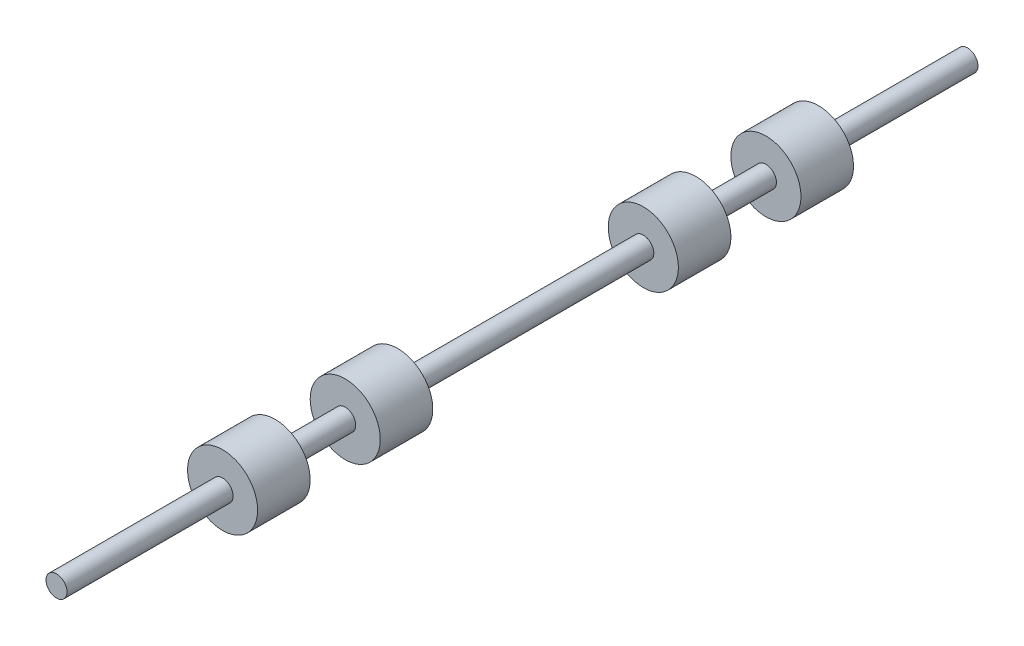
from build123d import *

# Parameters (mm, degrees)
SKETCH1_R           = 0.3
BOSS_EXTRUDE1_DEPTH = 26
SKETCH2_W           = 1
SKETCH2_H           = 1.5


with BuildPart() as part:
    # Sketch1 → Boss-Extrude1 (new body)
    with BuildSketch(Plane.XY):
        Circle(SKETCH1_R)
    extrude(amount=BOSS_EXTRUDE1_DEPTH)

    # Sketch2 → Revolve1 (revolve)
    with BuildSketch(Plane(origin=(0, 0, 0), x_dir=(1, 0, 0), z_dir=(0, 1, 0))):
        with Locations((0.5, -5.003)):
            Rectangle(SKETCH2_W, SKETCH2_H)
        with Locations((0.5, -8.503)):
            Rectangle(SKETCH2_W, SKETCH2_H)
        with Locations((0.5, -17.01)):
            Rectangle(SKETCH2_W, SKETCH2_H)
        with Locations((0.5, -20.51)):
            Rectangle(SKETCH2_W, SKETCH2_H)
    revolve(axis=Axis((0, 0, 0), (0, 0, 1)))


solid = part.part
